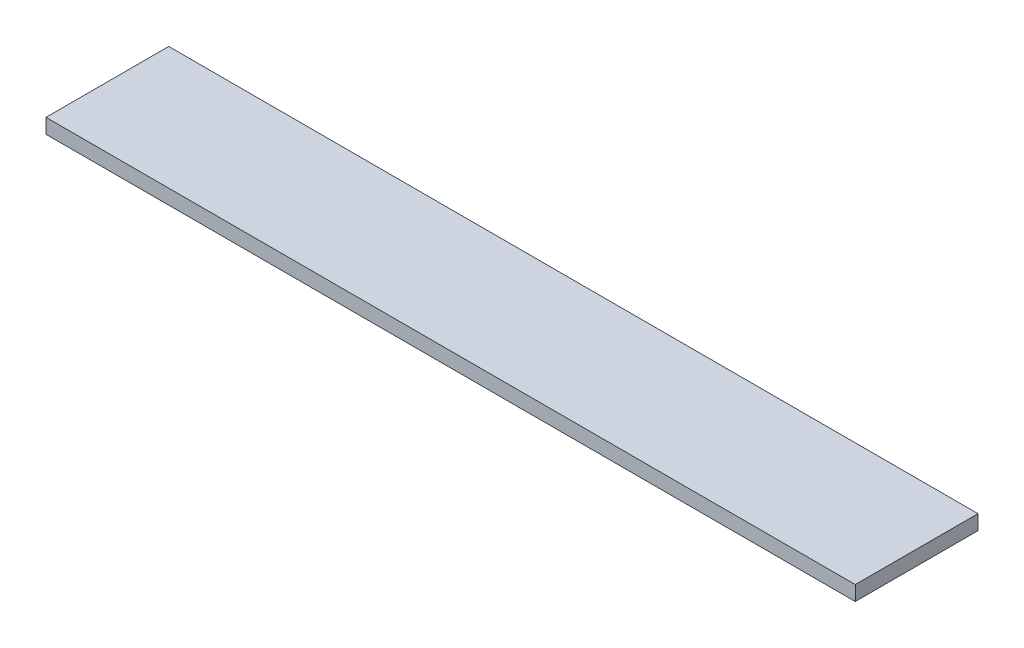
from build123d import *

# Parameters (mm, degrees)
SKETCH1_W           = 989
SKETCH1_H           = 150
BOSS_EXTRUDE1_DEPTH = 18


with BuildPart() as part:
    # Sketch1 → Boss-Extrude1 (new body)
    with BuildSketch(Plane(origin=(0, 0, 0), x_dir=(1, 0, 0), z_dir=(0, 1, 0))):
        Rectangle(SKETCH1_W, SKETCH1_H)
    extrude(amount=BOSS_EXTRUDE1_DEPTH)


solid = part.part
